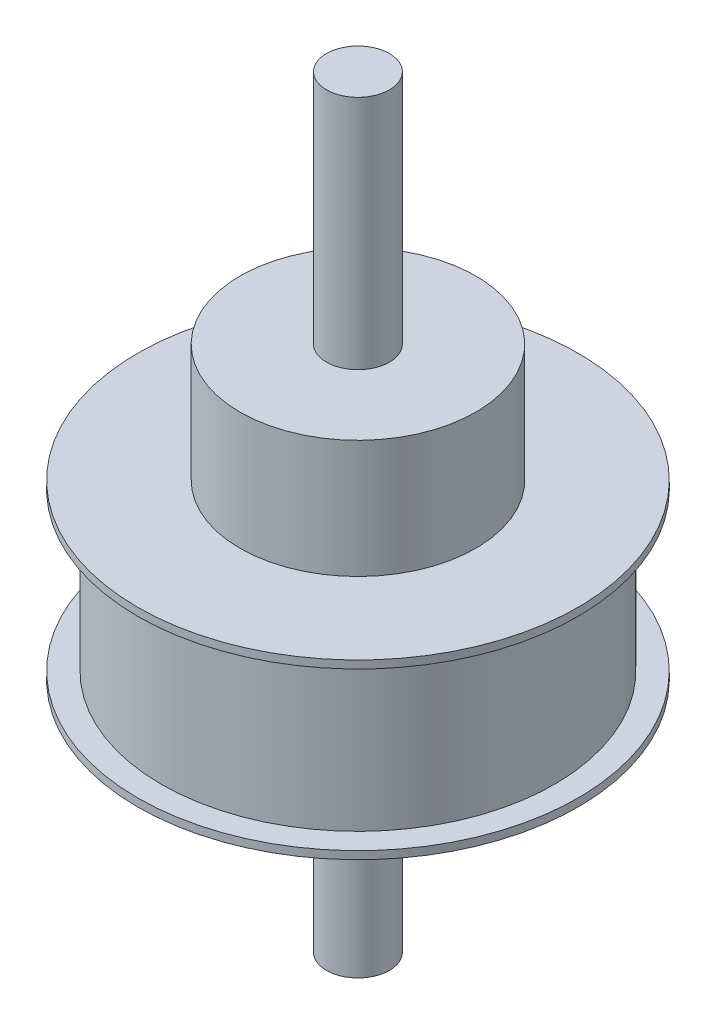
from build123d import *

# Parameters (mm, degrees)
SKETCH1_R           = 25
BOSS_EXTRUDE1_DEPTH = 21
SKETCH2_R           = 28
BOSS_EXTRUDE2_DEPTH = 1
SKETCH3_R           = 28
BOSS_EXTRUDE3_DEPTH = 1
SKETCH4_R           = 15
BOSS_EXTRUDE4_DEPTH = 15
SKETCH5_R           = 4
BOSS_EXTRUDE5_DEPTH = 30
SKETCH6_R           = 4
BOSS_EXTRUDE6_DEPTH = 30


with BuildPart() as part:
    # Sketch1 → Boss-Extrude1 (new body)
    with BuildSketch(Plane(origin=(0, 0, 0), x_dir=(1, 0, 0), z_dir=(0, 1, 0))):
        Circle(SKETCH1_R)
    extrude(amount=BOSS_EXTRUDE1_DEPTH)

    # Sketch2 → Boss-Extrude2 (add)
    with BuildSketch(Plane(origin=(0, 0, 0), x_dir=(1, 0, 0), z_dir=(0, 1, 0))):
        Circle(SKETCH2_R)
    extrude(amount=BOSS_EXTRUDE2_DEPTH)

    # Sketch3 → Boss-Extrude3 (add)
    with BuildSketch(Plane(origin=(0, 21, 0), x_dir=(1, 0, 0), z_dir=(0, 1, 0))):
        Circle(SKETCH3_R)
    extrude(amount=BOSS_EXTRUDE3_DEPTH)

    # Sketch4 → Boss-Extrude4 (add)
    with BuildSketch(Plane(origin=(0, 22, 0), x_dir=(1, 0, 0), z_dir=(0, 1, 0))):
        Circle(SKETCH4_R)
    extrude(amount=BOSS_EXTRUDE4_DEPTH)

    # Sketch5 → Boss-Extrude5 (add)
    with BuildSketch(Plane(origin=(0, 37, 0), x_dir=(1, 0, 0), z_dir=(0, 1, 0))):
        Circle(SKETCH5_R)
    extrude(amount=BOSS_EXTRUDE5_DEPTH)

    # Sketch6 → Boss-Extrude6 (add)
    with BuildSketch(Plane(origin=(0, 0, 0), x_dir=(1, 0, 0), z_dir=(0, 1, 0))):
        Circle(SKETCH6_R)
    extrude(amount=-BOSS_EXTRUDE6_DEPTH)


solid = part.part
